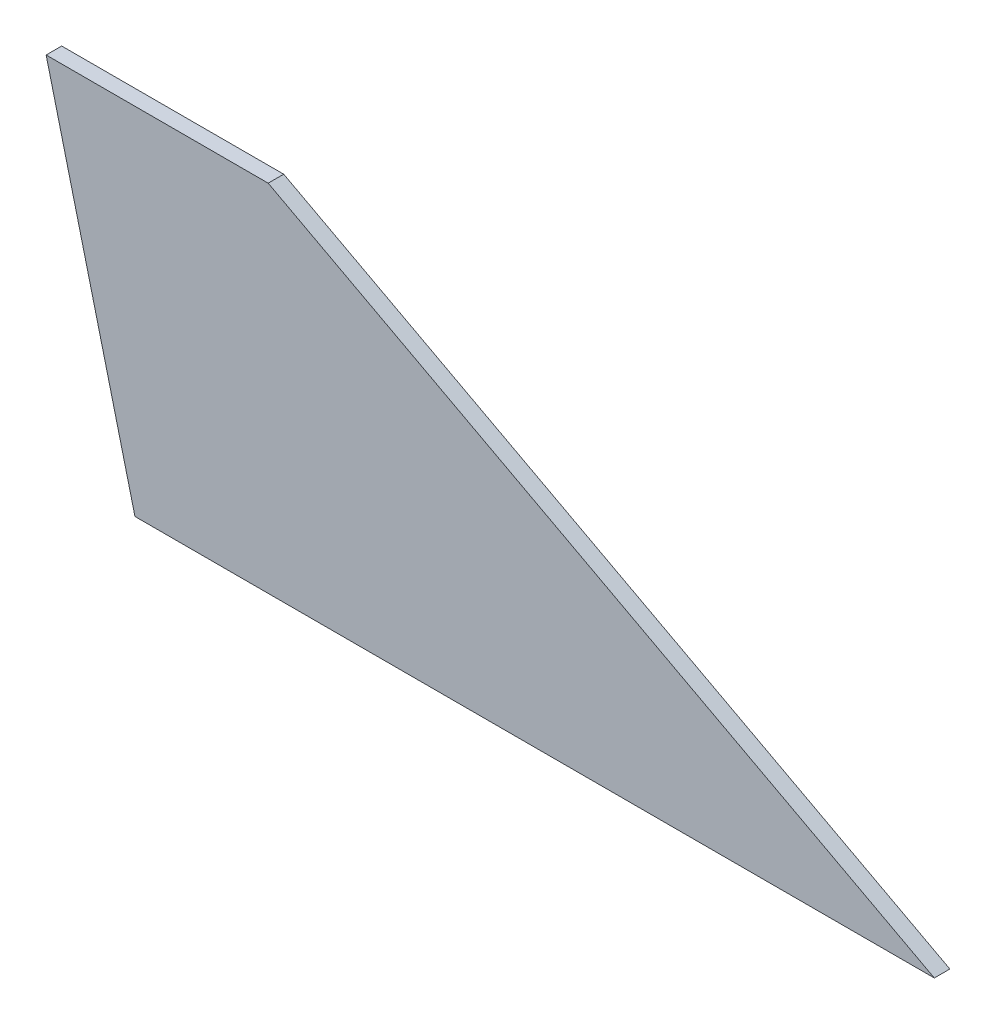
from build123d import *

# Parameters (mm, degrees)
BOSS_EXTRUDE1_DEPTH = 8.89


with BuildPart() as part:
    # Sketch1 → Boss-Extrude1 (new body)
    with BuildSketch(Plane.XY):
        Polygon((0, 0), (457.2, 0), (76.2, 203.2), (-50.8, 203.2), align=None)
    extrude(amount=BOSS_EXTRUDE1_DEPTH)


solid = part.part
